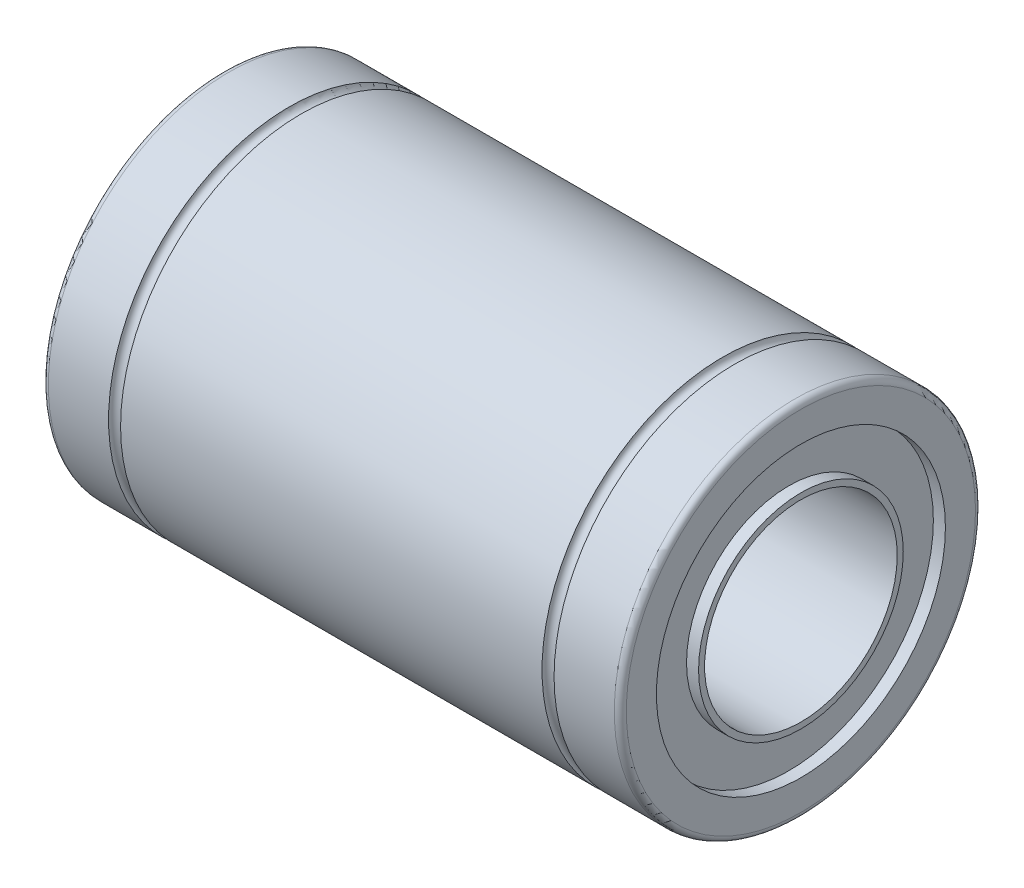
from build123d import *

# Parameters (mm, degrees)
EXTRUDE1_DEPTH      = 12
EXTRUDE1_DEPTH_BACK = 12
SKETCH2_R           = 7.5
SKETCH2_R_2         = 6
EXTRUDE2_DEPTH      = 12
EXTRUDE2_DEPTH_BACK = 12
SKETCH2_4_R         = 4.25
SKETCH2_4_R_2       = 4
EXTRUDE3_DEPTH      = 11.5
EXTRUDE3_DEPTH_BACK = 11.5
SKETCH2_5_R         = 6
SKETCH2_5_R_2       = 4.25
FILLET3_R           = 0.25
FILLET4_R           = 0.25
SKETCH3_R           = 0.25
SKETCH6_R           = 0.25


with BuildPart() as part:
    # Sketch2 → Extrude1 (new, two sides: drawn at the far end of the back side and taken through both)
    with BuildSketch(Plane(origin=(0, 0, 0), x_dir=(0, 0, -1), z_dir=(1, 0, 0)).offset(-EXTRUDE1_DEPTH_BACK)):
        Circle(SKETCH2_R)
        Circle(SKETCH2_R_2, mode=Mode.SUBTRACT)
    extrude(amount=EXTRUDE1_DEPTH + EXTRUDE1_DEPTH_BACK)



with BuildPart() as body_2:
    # Sketch2_4 → Extrude2 (new, two sides: drawn at the far end of the back side and taken through both)
    with BuildSketch(Plane(origin=(0, 0, 0), x_dir=(0, 0, -1), z_dir=(1, 0, 0)).offset(-EXTRUDE2_DEPTH_BACK)):
        Circle(SKETCH2_4_R)
        Circle(SKETCH2_4_R_2, mode=Mode.SUBTRACT)
    extrude(amount=EXTRUDE2_DEPTH + EXTRUDE2_DEPTH_BACK)


with BuildPart() as part_1:
    add(part.part)

    add(body_2.part)  # Extrude3 merges body 2
    # Sketch2_5 → Extrude3 (add, two sides: drawn at the far end of the back side and taken through both)
    with BuildSketch(Plane(origin=(0, 0, 0), x_dir=(0, 0, -1), z_dir=(1, 0, 0)).offset(-EXTRUDE3_DEPTH_BACK)):
        Circle(SKETCH2_5_R)
        Circle(SKETCH2_5_R_2, mode=Mode.SUBTRACT)
    extrude(amount=EXTRUDE3_DEPTH + EXTRUDE3_DEPTH_BACK)

    # Fillet3
    fillet3_edges = [part_1.edges().sort_by_distance(p)[0] for p in [
        (12, 0, 7.5),
    ]]
    fillet(fillet3_edges, radius=FILLET3_R)

    # Fillet4
    fillet4_edges = [part_1.edges().sort_by_distance(p)[0] for p in [
        (-12, 0, 7.5),
    ]]
    fillet(fillet4_edges, radius=FILLET4_R)

    # Cut-Sweep1: sweep along a path in Sketch4
    with BuildLine(Plane.ZY.offset(9)) as cut_sweep1_path:
        CenterArc((0, 0), 7.5, 0, 360)
    # Sketch3 → Cut-Sweep1 (sweep, cut)
    with BuildSketch(Plane(origin=(0, 0, 0), x_dir=(1, 0, 0), z_dir=(0, 1, 0))):
        with Locations((-9, 7.5)):
            Circle(SKETCH3_R)
    sweep(path=cut_sweep1_path.line, mode=Mode.SUBTRACT)

    # Cut-Sweep2: sweep along a path in Sketch7
    with BuildLine(Plane(origin=(9, 0, 0), x_dir=(0, 0, -1), z_dir=(1, 0, 0))) as cut_sweep2_path:
        CenterArc((0, 0), 7.5, 0, 360)
    # Sketch6 → Cut-Sweep2 (sweep, cut)
    with BuildSketch(Plane(origin=(0, 0, 0), x_dir=(1, 0, 0), z_dir=(0, 1, 0))):
        with Locations((9, 7.5)):
            Circle(SKETCH6_R)
    sweep(path=cut_sweep2_path.line, mode=Mode.SUBTRACT)


solid = part_1.part
